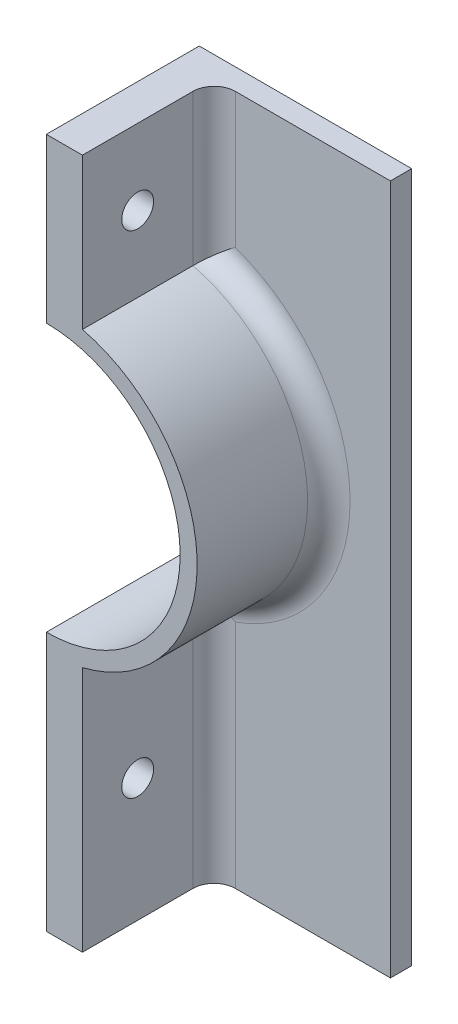
from build123d import *

# Parameters (mm, degrees)
BOSS_EXTRUDE6_DEPTH = 18.288
BOSS_EXTRUDE7_DEPTH = 2.54
SKETCH4_R           = 1.905
CUT_EXTRUDE2_DEPTH  = 51.8
FILLET2_R           = 2.54


with BuildPart() as part:
    # Sketch3 → Boss-Extrude6 (new body)
    with BuildSketch(Plane.XY):
        with BuildLine():
            Line((25.4, 30.988), (25.4, 0))
            Line((25.4, 0), (29.718, 0))
            Line((29.718, 0), (29.718, 29.480573053))
            ThreePointArc((29.718, 29.480573053), (43.434, 46.99), (29.718, 64.499426947))
            Line((29.718, 64.499426947), (29.718, 82.55))
            Line((29.718, 82.55), (25.4, 82.55))
            Line((25.4, 82.55), (25.4, 62.992))
            ThreePointArc((25.4, 62.992), (36.715122713, 58.305122713), (41.402, 46.99))
            ThreePointArc((41.402, 46.99), (36.715122713, 35.674877287), (25.4, 30.988))
        make_face()
    extrude(amount=BOSS_EXTRUDE6_DEPTH)

    # Sketch3_10 → Boss-Extrude7 (add)
    with BuildSketch(Plane.XY):
        with BuildLine():
            Line((29.718, 29.480573053), (29.718, 0))
            Line((29.718, 0), (50.8, 0))
            Line((50.8, 0), (50.8, 82.55))
            Line((50.8, 82.55), (29.718, 82.55))
            Line((29.718, 82.55), (29.718, 64.499426947))
            ThreePointArc((29.718, 64.499426947), (43.434, 46.99), (29.718, 29.480573053))
        make_face()
    extrude(amount=BOSS_EXTRUDE7_DEPTH)

    # Sketch4 → Cut-Extrude2 (cut, through all)
    with BuildSketch(Plane(origin=(0, 0, 0), x_dir=(0, 0, -1), z_dir=(1, 0, 0))):
        with Locations((-11.684, 14.740286527)):
            Circle(SKETCH4_R)
        with Locations((-11.684, 73.524713473)):
            Circle(SKETCH4_R)
    extrude(amount=CUT_EXTRUDE2_DEPTH, mode=Mode.SUBTRACT)

    # Fillet2
    fillet2_edges = [part.edges().sort_by_distance(p)[0] for p in [
        (43.434, 46.99, 2.54),
        (29.718, 14.740286527, 2.54),
        (29.718, 73.524713473, 2.54),
    ]]
    fillet(fillet2_edges, radius=FILLET2_R)


solid = part.part
